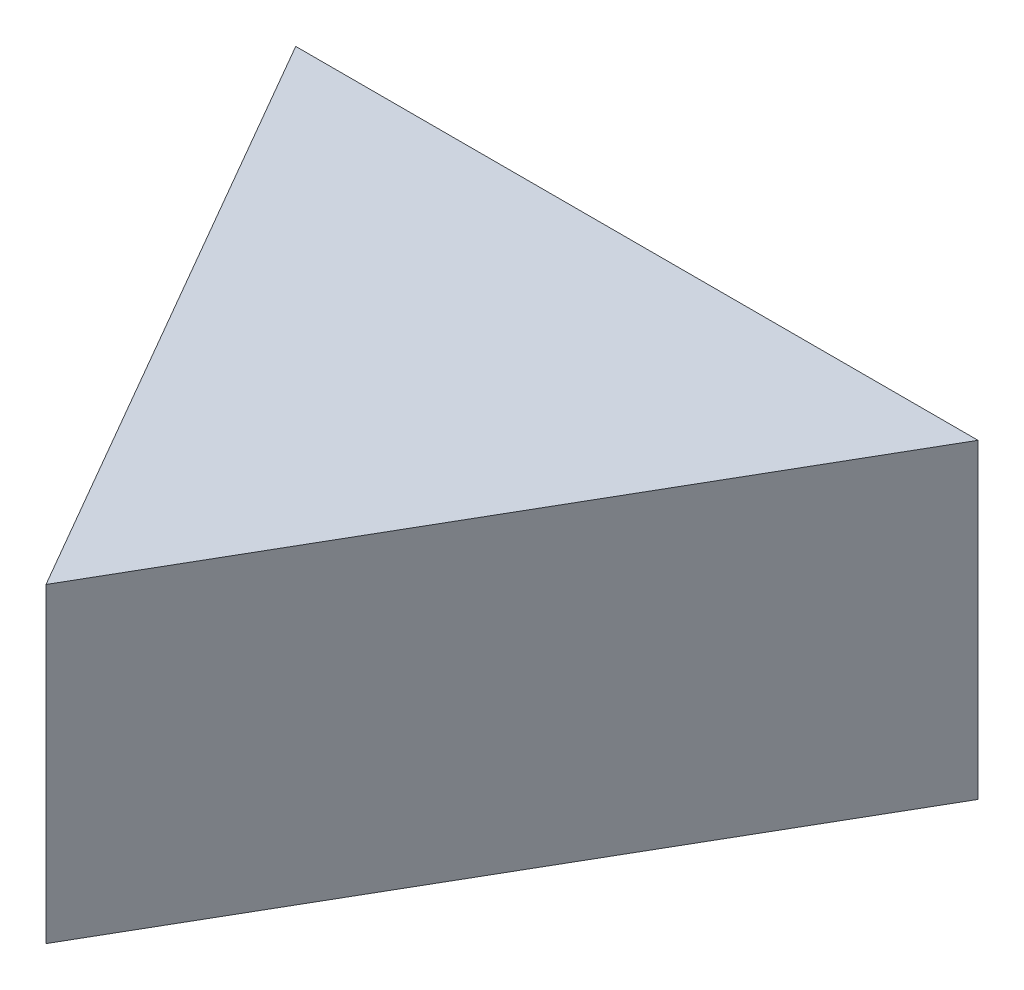
from build123d import *

# Parameters (mm, degrees)
BOSS_EXTRUDE1_DEPTH = 38.1


with BuildPart() as part:
    # Sketch1 → Boss-Extrude1 (new body)
    with BuildSketch(Plane(origin=(0, 0, 0), x_dir=(1, 0, 0), z_dir=(0, 1, 0))):
        Polygon((44.45, 0), (86.238319366, 72.379492305), (2.661680634, 72.379492305), align=None)
    extrude(amount=BOSS_EXTRUDE1_DEPTH)


solid = part.part
